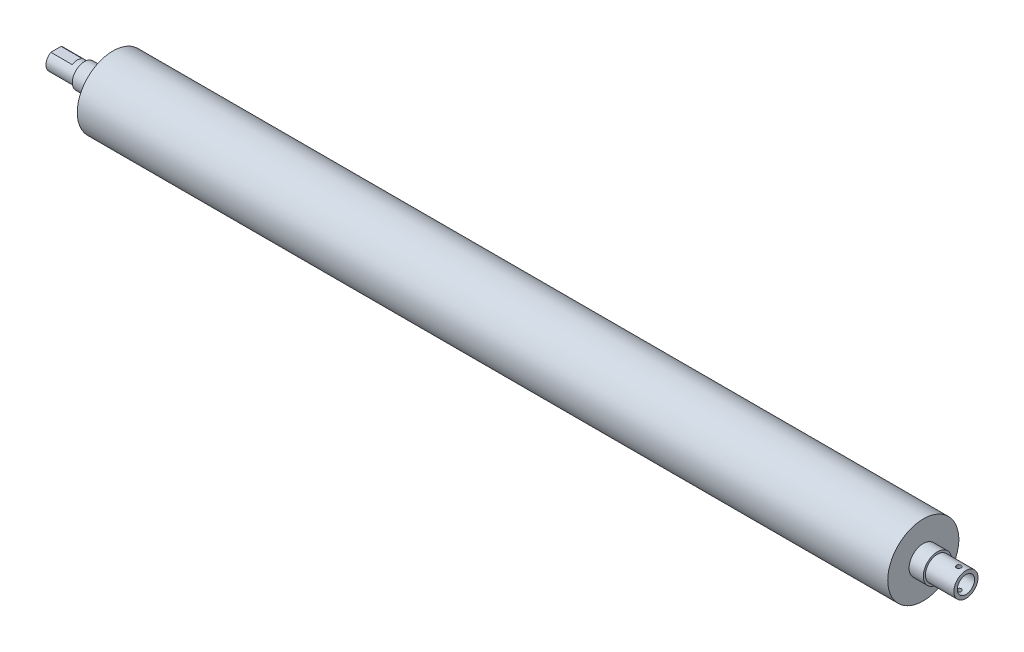
from build123d import *

# Parameters (mm, degrees)
CUT_EXTRUDE_2_DEPTH    = 15
MM_CLEARANCE_1_D       = 12.1
MM_CLEARANCE_1_DEPTH   = 12
MM_CLEARANCE_1_TIP     = 3.635206745
HOLE_WIZARD_M4_3_D     = 3.3
HOLE_WIZARD_M4_3_DEPTH = 25
HOLE_WIZARD_M4_3_TIP   = 0.991420021


with BuildPart() as part:
    # 草图2 → 旋转1 (revolve)
    with BuildSketch(Plane.XY):
        Polygon((554.440585902, 10), (544.440585902, 10), (544.440585902, 25), (-25.559414098, 25), (-25.559414098, 10), (-35.559414098, 10), (-35.559414098, 8.5), (-45.559414098, 8.5), (-45.559414098, 7), (-65.559414098, 7), (-65.559414098, 0), (-51.631049649, 0), (574.440585902, 0), (574.440585902, 8.5), (554.440585902, 8.5), align=None)
    revolve(axis=Axis((-62.705882353, 0, 0), (1, 0, 0)))

    # 草图4 → 切除-拉伸2 (cut)
    with BuildSketch(Plane.ZY.offset(65.559414098)):
        with BuildLine():
            Line((-8, 6), (8, 6))
            ThreePointArc((8, 6), (0, 10), (-8, 6))
        make_face()
    extrude(amount=-CUT_EXTRUDE_2_DEPTH, mode=Mode.SUBTRACT)

    # 大小mm Clearance 暗销孔1
    with Locations(Plane(origin=(574.440585902, 0, 0), x_dir=(0, 0, -1), z_dir=(1, 0, 0))):
        with Locations((0, 0)):
            Hole(MM_CLEARANCE_1_D / 2, depth=MM_CLEARANCE_1_DEPTH)
            with Locations((0, 0, -(MM_CLEARANCE_1_DEPTH + MM_CLEARANCE_1_TIP / 2))):  # 118° drill point
                Cone(0, MM_CLEARANCE_1_D / 2, MM_CLEARANCE_1_TIP, mode=Mode.SUBTRACT)

    # M4 螺纹孔3
    with Locations(Plane(origin=(0, 8.5, 0), x_dir=(1, 0, 0), z_dir=(0, 1, 0))):
        with Locations((569.440585902, 0)):
            Hole(HOLE_WIZARD_M4_3_D / 2, depth=HOLE_WIZARD_M4_3_DEPTH)
            with Locations((0, 0, -(HOLE_WIZARD_M4_3_DEPTH + HOLE_WIZARD_M4_3_TIP / 2))):  # 118° drill point
                Cone(0, HOLE_WIZARD_M4_3_D / 2, HOLE_WIZARD_M4_3_TIP, mode=Mode.SUBTRACT)


solid = part.part
